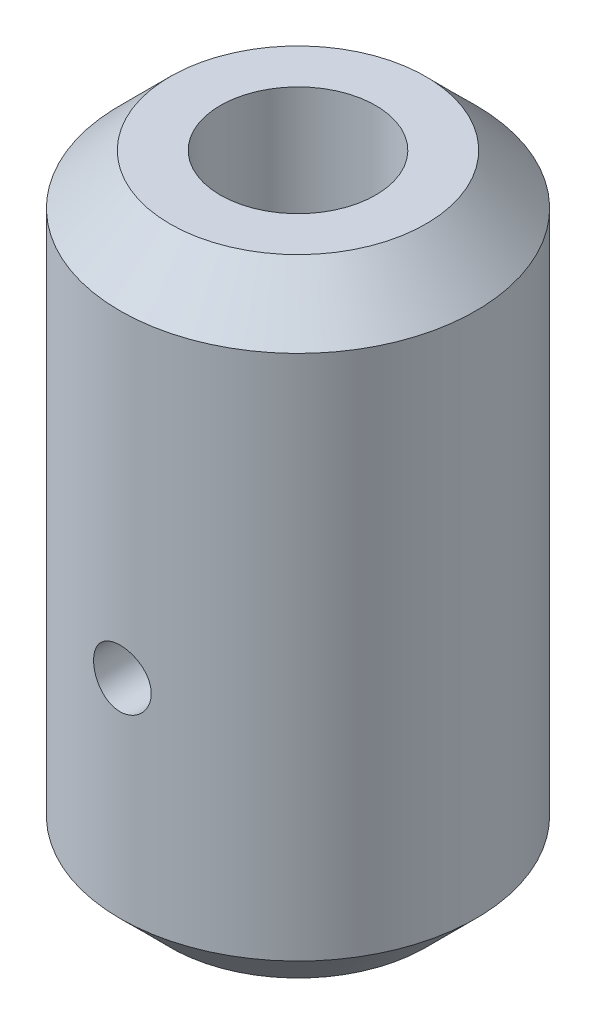
from build123d import *

# Parameters (mm, degrees)
SKETCH1_R               = 7.1
SKETCH1_R_2             = 3.1
BOSS_EXTRUDE1_DEPTH     = 20
SKETCH3_R               = 1.15
CUT_EXTRUDE1_DEPTH      = 8.1
CUT_EXTRUDE1_DEPTH_BACK = 8.1
CUT_EXTRUDE2_START      = -4
SKETCH5_R               = 1.8
CUT_EXTRUDE2_DEPTH      = 5
SKETCH2_R               = 7.1
BOSS_EXTRUDE2_DEPTH     = 5
CHAMFER1_SIZE           = 2


with BuildPart() as part:
    # Sketch1 → Boss-Extrude1 (new body)
    with BuildSketch(Plane(origin=(0, 0, 0), x_dir=(1, 0, 0), z_dir=(0, 1, 0))):
        Circle(SKETCH1_R)
        Circle(SKETCH1_R_2, mode=Mode.SUBTRACT)
    extrude(amount=BOSS_EXTRUDE1_DEPTH)

    # Sketch3 → Cut-Extrude1 (cut, two sides)
    with BuildSketch(Plane.XY) as cut_extrude1_sk:
        with Locations((0, 5.3)):
            Circle(SKETCH3_R)
    extrude(amount=CUT_EXTRUDE1_DEPTH, mode=Mode.SUBTRACT)
    extrude(cut_extrude1_sk.sketch, amount=-CUT_EXTRUDE1_DEPTH_BACK, mode=Mode.SUBTRACT)

    # Sketch5 → Cut-Extrude2 (cut)
    with BuildSketch(Plane.XY.offset(CUT_EXTRUDE2_START)):
        with Locations((0, 5.3)):
            Circle(SKETCH5_R)
    extrude(amount=-CUT_EXTRUDE2_DEPTH, mode=Mode.SUBTRACT)

    # Sketch2 → Boss-Extrude2 (add)
    with BuildSketch(Plane.XZ):
        Circle(SKETCH2_R)
    extrude(amount=BOSS_EXTRUDE2_DEPTH)

    # Chamfer1
    chamfer1_edges = [part.edges().sort_by_distance(p)[0] for p in [
        (-7.1, -5, 0),
        (-7.1, 20, 0),
    ]]
    chamfer(chamfer1_edges, length=CHAMFER1_SIZE)


solid = part.part
